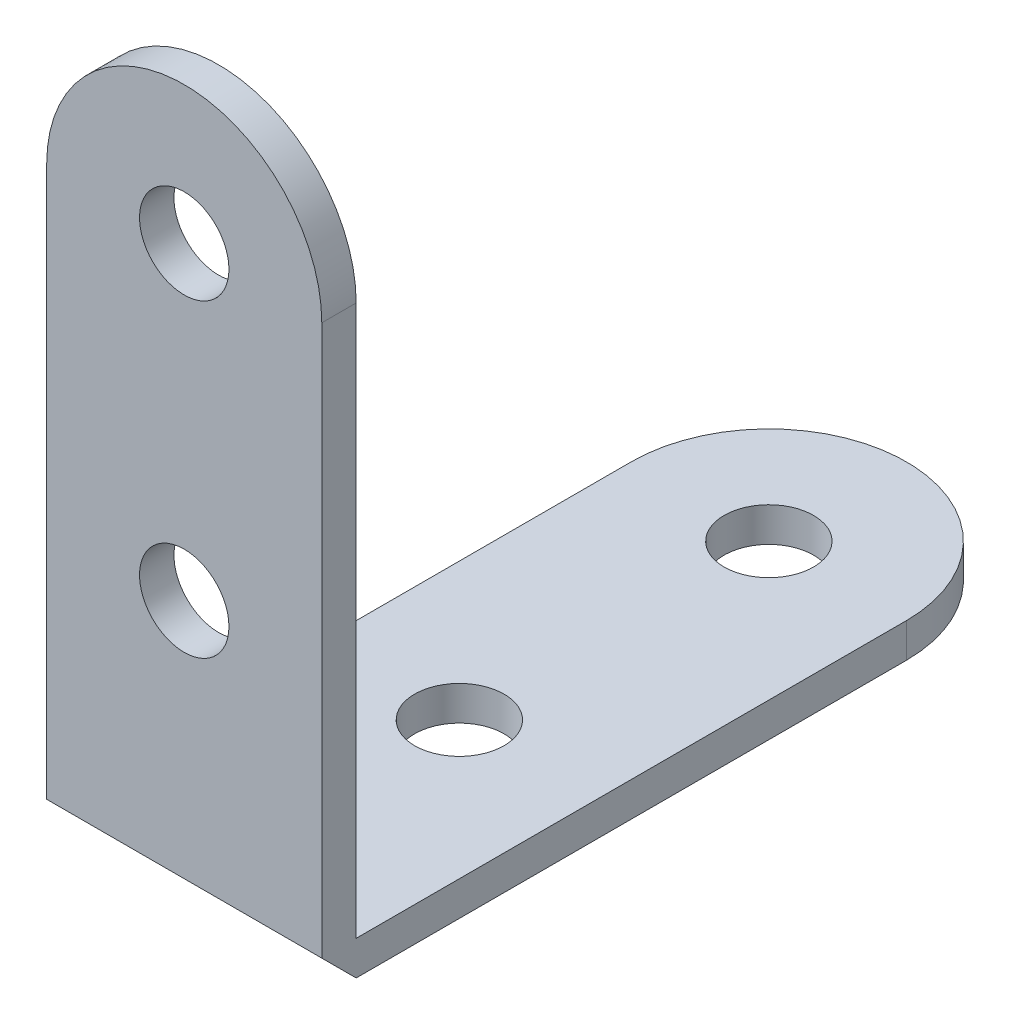
from build123d import *

# Parameters (mm, degrees)
SKETCH_1_R      = 2.6
EXTRUDE_1_DEPTH = 2
SKETCH_2_R      = 2.6
EXTRUDE_2_DEPTH = 2
EXTRUDE_3_DEPTH = 16


with BuildPart() as part:
    # 草图1 → 凸台-拉伸1 (new body)
    with BuildSketch(Plane.XY):
        with BuildLine():
            Line((-8, 32), (-8, 0))
            Line((-8, 0), (8, 0))
            Line((8, 0), (8, 32))
            ThreePointArc((8, 32), (0, 40), (-8, 32))
        make_face()
        with Locations((0, 32)):
            Circle(SKETCH_1_R, mode=Mode.SUBTRACT)
        with Locations((0, 14)):
            Circle(SKETCH_1_R, mode=Mode.SUBTRACT)
    extrude(amount=EXTRUDE_1_DEPTH)



with BuildPart() as body_2:
    # 草图2 → 凸台-拉伸2 (new body)
    with BuildSketch(Plane(origin=(0, 0, 0), x_dir=(1, 0, 0), z_dir=(0, 1, 0))):
        with BuildLine():
            Line((-8, 32), (-8, 0))
            Line((-8, 0), (8, 0))
            Line((8, 0), (8, 32))
            ThreePointArc((8, 32), (0, 40), (-8, 32))
        make_face()
        with Locations((0, 32)):
            Circle(SKETCH_2_R, mode=Mode.SUBTRACT)
        with Locations((0, 14)):
            Circle(SKETCH_2_R, mode=Mode.SUBTRACT)
    extrude(amount=-EXTRUDE_2_DEPTH)


with BuildPart() as part_1:
    add(part.part)

    add(body_2.part)  # 凸台-拉伸3 merges body 2
    # 草图3 → 凸台-拉伸3 (add)
    with BuildSketch(Plane(origin=(8, 0, 0), x_dir=(0, 0, -1), z_dir=(1, 0, 0))):
        Polygon((0, 0), (0, -2), (-2, 0), align=None)
    extrude(amount=-EXTRUDE_3_DEPTH)


solid = part_1.part
